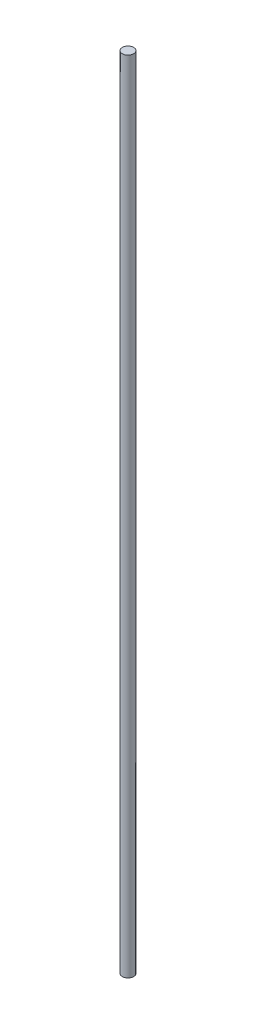
from build123d import *

# Parameters (mm, degrees)
SKETCH1_R           = 4
BOSS_EXTRUDE1_DEPTH = 570


with BuildPart() as part:
    # Sketch1 → Boss-Extrude1 (new body)
    with BuildSketch(Plane(origin=(0, 0, 0), x_dir=(1, 0, 0), z_dir=(0, 1, 0))):
        Circle(SKETCH1_R)
    extrude(amount=BOSS_EXTRUDE1_DEPTH)


solid = part.part
